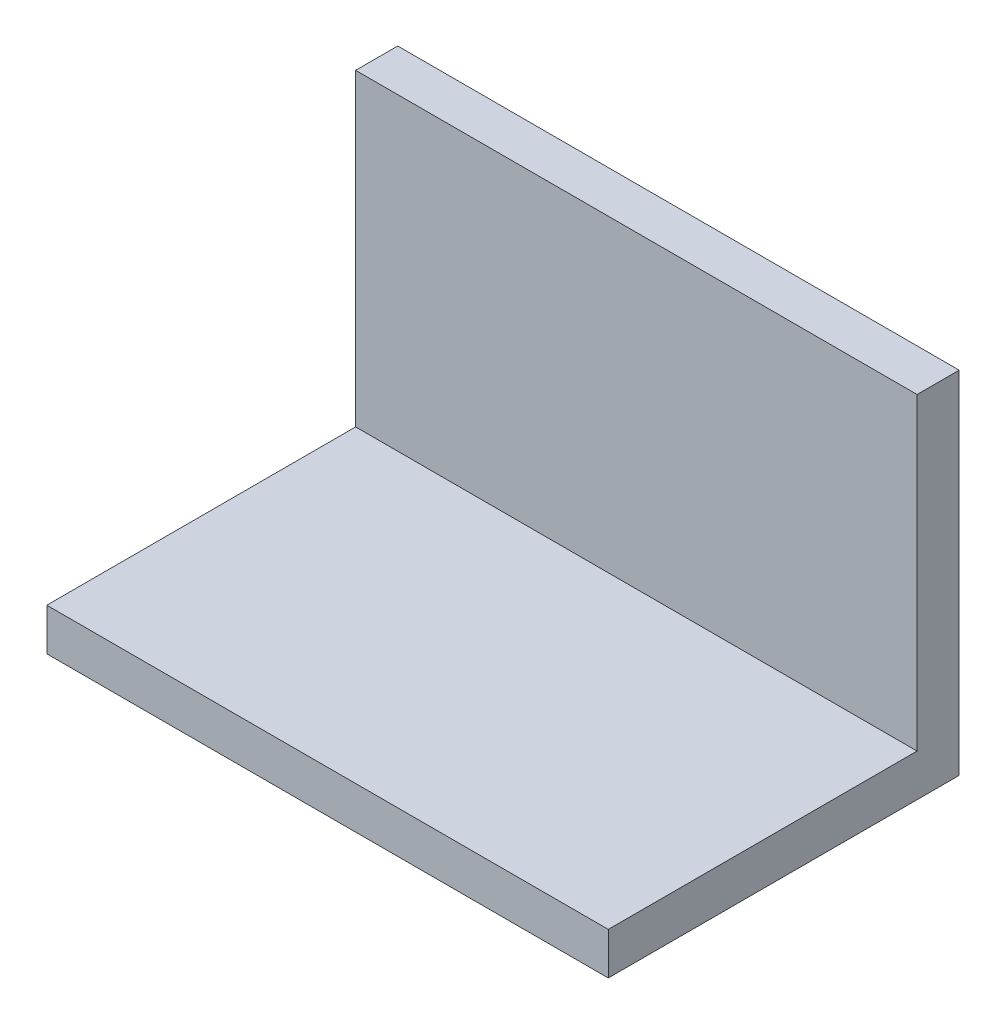
from build123d import *

# Parameters (mm, degrees)
CROQUIS1_W              = 80
CROQUIS1_H              = 50
SALIENTE_EXTRUIR1_DEPTH = 6
CROQUIS2_W              = 80
CROQUIS2_H              = 6
SALIENTE_EXTRUIR2_DEPTH = 44


with BuildPart() as part:
    # Croquis1 → Saliente-Extruir1 (new body)
    with BuildSketch(Plane(origin=(0, 0, 0), x_dir=(1, 0, 0), z_dir=(0, 1, 0))):
        Rectangle(CROQUIS1_W, CROQUIS1_H)
    extrude(amount=SALIENTE_EXTRUIR1_DEPTH)

    # Croquis2 → Saliente-Extruir2 (add)
    with BuildSketch(Plane(origin=(0, 6, 0), x_dir=(1, 0, 0), z_dir=(0, 1, 0))):
        with Locations((0, 22)):
            Rectangle(CROQUIS2_W, CROQUIS2_H)
    extrude(amount=SALIENTE_EXTRUIR2_DEPTH)


solid = part.part
